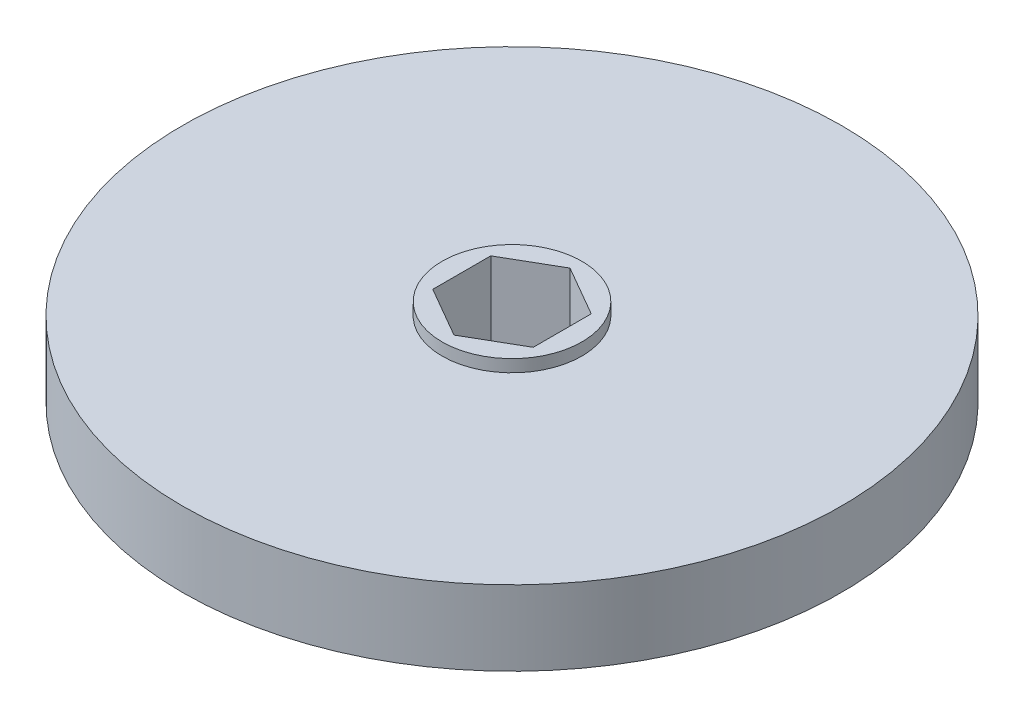
from build123d import *

# Parameters (mm, degrees)
SKETCH1_R           = 41.91
BOSS_EXTRUDE1_DEPTH = 4.7625
SKETCH2_R           = 8.89
BOSS_EXTRUDE2_DEPTH = 6.3246
CUT_EXTRUDE1_DEPTH  = 13.6492


with BuildPart() as part:
    # Sketch1 → Boss-Extrude1 (new body, symmetric)
    with BuildSketch(Plane(origin=(0, 0, 0), x_dir=(1, 0, 0), z_dir=(0, 1, 0))):
        Circle(SKETCH1_R)
    extrude(amount=BOSS_EXTRUDE1_DEPTH, both=True)

    # Sketch2 → Boss-Extrude2 (add, symmetric)
    with BuildSketch(Plane(origin=(0, 0, 0), x_dir=(1, 0, 0), z_dir=(0, 1, 0))):
        Circle(SKETCH2_R)
    extrude(amount=BOSS_EXTRUDE2_DEPTH, both=True)

    # Sketch3 → Cut-Extrude1 (cut, through all)
    with BuildSketch(Plane(origin=(0, 6.3246, 0), x_dir=(1, 0, 0), z_dir=(0, 1, 0))):
        Polygon((0, 7.376342509), (-6.3881, 3.688171255), (-6.3881, -3.688171255), (0, -7.376342509), (6.3881, -3.688171255), (6.3881, 3.688171255), align=None)
    extrude(amount=-CUT_EXTRUDE1_DEPTH, mode=Mode.SUBTRACT)


solid = part.part
